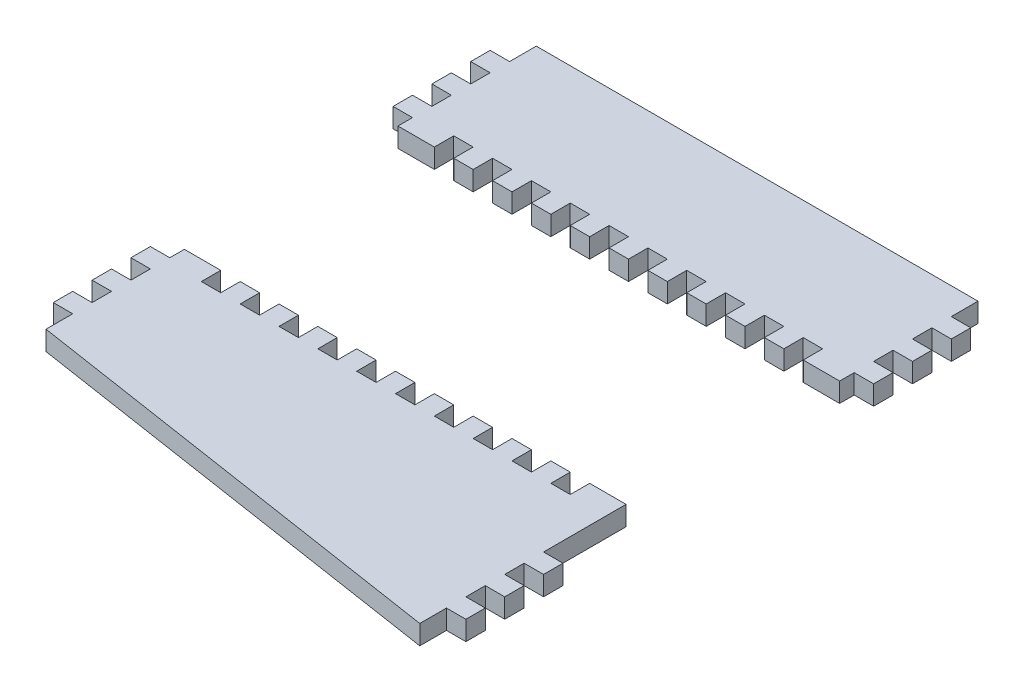
from build123d import *

# Parameters (mm, degrees)
BOSS_EXTRUDE1_DEPTH = 4
SKETCH4_W           = 141.578614927
SKETCH4_H           = 44
CUT_EXTRUDE1_DEPTH  = 4
CUT_EXTRUDE3_DEPTH  = 4


with BuildPart() as part:
    # Sketch1 → Boss-Extrude1 (new body)
    with BuildSketch(Plane(origin=(0, 0, 0), x_dir=(1, 0, 0), z_dir=(0, 1, 0))):
        Polygon((-14.478713339, 45), (-18.478713339, 45), (-18.478713339, 41), (-14.478713339, 41), (-14.478713339, 37), (-18.478713339, 37), (-18.478713339, 33), (-14.478713339, 33), (-14.478713339, 29), (-18.478713339, 29), (-18.478713339, 25), (-14.478713339, 25), (-14.478713339, -25), (-18.478713339, -25), (-18.478713339, -29), (-14.478713339, -29), (-14.478713339, -33), (-18.478713339, -33), (-18.478713339, -37), (-14.478713339, -37), (-14.478713339, -41), (-18.478713339, -41), (-18.478713339, -45), (-14.478713339, -45), (-14.478713339, -50.5), (76.521286661, -64.5), (76.521286661, -59), (80.521286661, -59), (80.521286661, -55), (76.521286661, -55), (76.521286661, -51), (80.521286661, -51), (80.521286661, -47), (76.521286661, -47), (76.521286661, -43), (80.521286661, -43), (80.521286661, -39), (76.521286661, -39), (76.521286661, 25), (80.521286661, 25), (80.521286661, 29), (76.521286661, 29), (76.521286661, 33), (80.521286661, 33), (80.521286661, 37), (76.521286661, 37), (76.521286661, 41), (80.521286661, 41), (80.521286661, 45), (76.521286661, 45), (76.521286661, 50.5), (-14.478713339, 50.5), align=None)
    extrude(amount=BOSS_EXTRUDE1_DEPTH)

    # Sketch4 → Cut-Extrude1 (cut)
    with BuildSketch(Plane(origin=(0, 4, 0), x_dir=(1, 0, 0), z_dir=(0, 1, 0))):
        with Locations((40.105465911, 0)):
            Rectangle(SKETCH4_W, SKETCH4_H)
    extrude(amount=-CUT_EXTRUDE1_DEPTH, mode=Mode.SUBTRACT)

    # Sketch5 → Cut-Extrude3 (cut)
    with BuildSketch(Plane(origin=(0, 4, 0), x_dir=(1, 0, 0), z_dir=(0, 1, 0))):
        Polygon((29.021286661, 22), (33.021286661, 22), (33.021286661, 26), (37.021286661, 26), (37.021286661, 22), (41.021286661, 22), (41.021286661, 26), (45.021286661, 26), (45.021286661, 22), (49.021286661, 22), (49.021286661, 26), (53.021286661, 26), (53.021286661, 22), (57.021286661, 22), (57.021286661, 26), (61.021286661, 26), (61.021286661, 22), (65.021286661, 22), (65.021286661, 26), (69.021286661, 26), (69.021286661, 22), (73.021286661, 22), (73.021286661, 13.939001522), (-10.978713339, 13.939001522), (-10.978713339, 22), (-6.978713339, 22), (-6.978713339, 26), (-2.978713339, 26), (-2.978713339, 22), (1.021286661, 22), (1.021286661, 26), (5.021286661, 26), (5.021286661, 22), (9.021286661, 22), (9.021286661, 26), (13.021286661, 26), (13.021286661, 22), (17.021286661, 22), (17.021286661, 26), (21.021286661, 26), (21.021286661, 22), (25.021286661, 22), (25.021286661, 26), (29.021286661, 26), align=None)
        Polygon((29.021286661, -22), (29.021286661, -26), (25.021286661, -26), (25.021286661, -22), (21.021286661, -22), (21.021286661, -26), (17.021286661, -26), (17.021286661, -22), (13.021286661, -22), (13.021286661, -26), (9.021286661, -26), (9.021286661, -22), (5.021286661, -22), (5.021286661, -26), (1.021286661, -26), (1.021286661, -22), (-2.978713339, -22), (-2.978713339, -26), (-6.978713339, -26), (-6.978713339, -22), (-10.978713339, -22), (-10.978713339, -13.939001522), (73.021286661, -13.939001522), (73.021286661, -22), (69.021286661, -22), (69.021286661, -26), (65.021286661, -26), (65.021286661, -22), (61.021286661, -22), (61.021286661, -26), (57.021286661, -26), (57.021286661, -22), (53.021286661, -22), (53.021286661, -26), (49.021286661, -26), (49.021286661, -22), (45.021286661, -22), (45.021286661, -26), (41.021286661, -26), (41.021286661, -22), (37.021286661, -22), (37.021286661, -26), (33.021286661, -26), (33.021286661, -22), align=None)
    extrude(amount=-CUT_EXTRUDE3_DEPTH, mode=Mode.SUBTRACT)


solid = part.part
